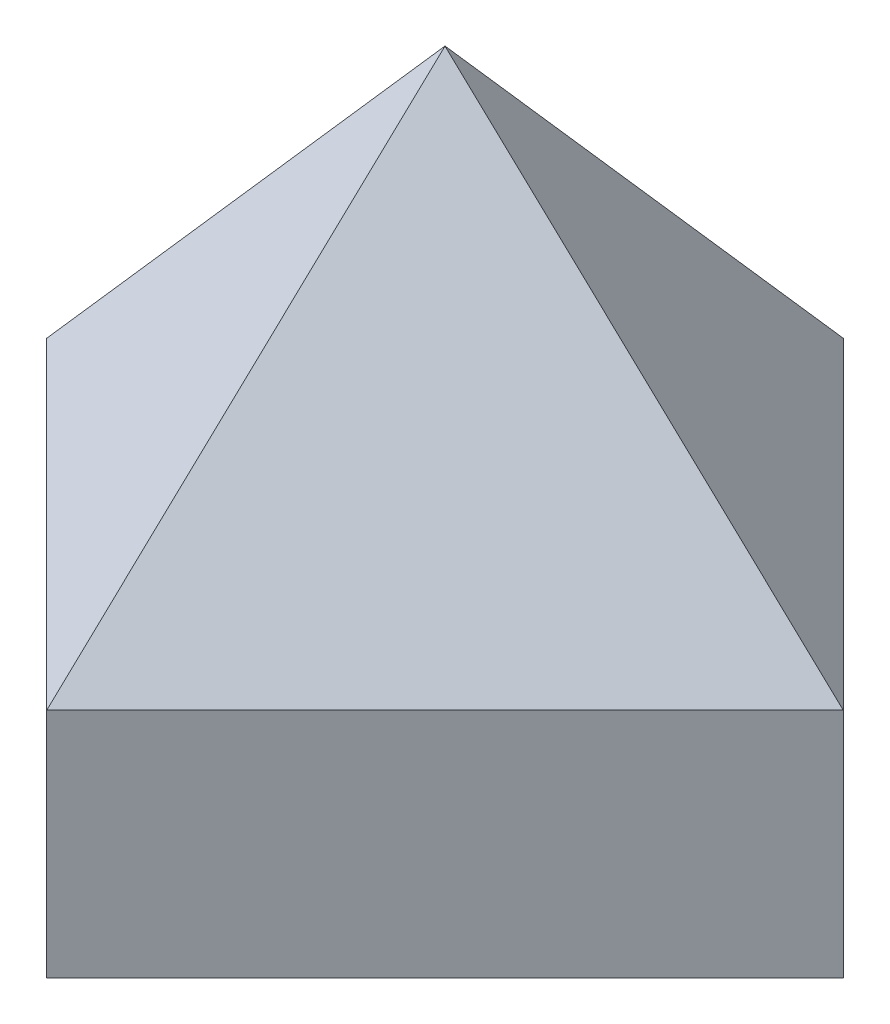
from build123d import *

# Parameters (mm, degrees)
EXTRUDE1_DEPTH = 28


with BuildPart() as part:
    # Sketch1 → Extrude1 (new body)
    with BuildSketch(Plane(origin=(0, 0, 0), x_dir=(1, 0, 0), z_dir=(0, 1, 0))):
        Polygon((-35.527943991, -10), (3.362928975, -48.890872965), (-44.720332146, -96.974134086), (-83.611205111, -58.083261121), align=None)
    extrude(amount=EXTRUDE1_DEPTH)

    # Sketch2 → Loft1 section 0
    with BuildSketch(Plane(origin=(0, 28, 0), x_dir=(-1, 0, 0), z_dir=(0, 1, 0)), mode=Mode.PRIVATE) as loft1_s0:
        Polygon((35.527943991, 10), (-3.362928975, 48.890872965), (44.720332146, 96.974134086), (83.611205111, 58.083261121), align=None)
    loft([Vertex(-40.124138068, 78, 53.487067043), loft1_s0.sketch])


solid = part.part
